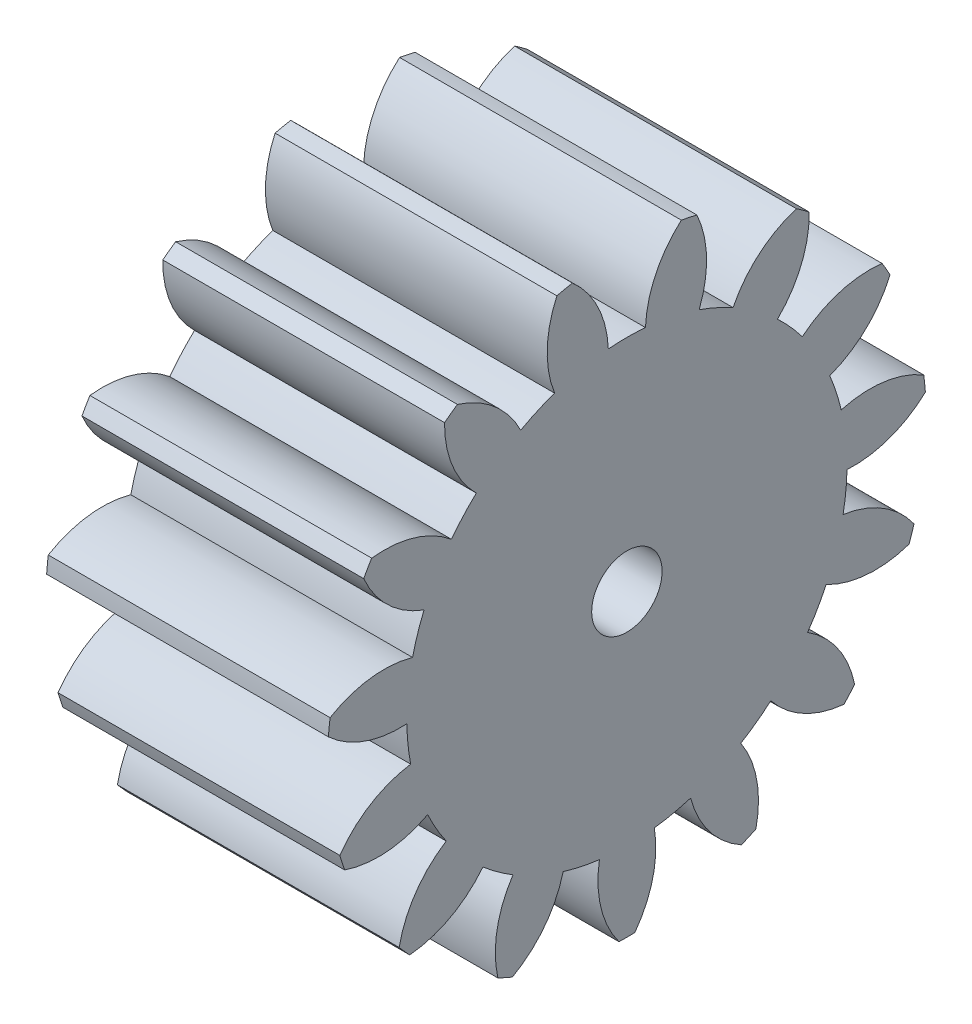
from build123d import *

# Parameters (mm, degrees)
BASPROSKE_W     = 20
BASPROSKE_H     = 21.25
TOOTHCUT_DEPTH  = 37.098822695
TEETHCUTS_COUNT = 15
TEETHCUTS_ANGLE = 336
BORSKE_R        = 2.5
BORE_DEPTH      = 50.0000508


with BuildPart() as part:
    # BasProSke → Base-Revolve (revolve)
    with BuildSketch(Plane(origin=(0, 0, 0), x_dir=(1, 0, 0), z_dir=(0, 1, 0)), mode=Mode.PRIVATE) as base_revolve_sk:
        with Locations((10, 10.625)):
            Rectangle(BASPROSKE_W, BASPROSKE_H)
    revolve(base_revolve_sk.sketch.rotate(Axis((-10, 0, 0), (1, 0, 0)), 180), axis=Axis((-10, 0, 0), (1, 0, 0)))

    # TooCutSke → ToothCut (cut, through all)
    with BuildSketch(Plane(origin=(0, 0, 0), x_dir=(0, 0, -1), z_dir=(1, 0, 0))):
        with BuildLine():
            ThreePointArc((1.317325472, 15.568366311), (0, 15.624), (-1.317325472, 15.568366311))
            ThreePointArc((-1.317325472, 15.568366311), (-2.05158513, 18.507838886), (-3.888921189, 20.916953343))
            ThreePointArc((-3.888921189, 20.916953343), (0, 21.2754), (3.888921189, 20.916953343))
            ThreePointArc((3.888921189, 20.916953343), (2.05158513, 18.507838886), (1.317325472, 15.568366311))
        make_face()
    toothcut = extrude(amount=TOOTHCUT_DEPTH, mode=Mode.SUBTRACT)

    # TeethCuts: ToothCut ×15 about axis
    teethcuts_axis = Axis((-10, 0, 0), (1, 0, 0))
    for i in range(1, TEETHCUTS_COUNT):
        add(toothcut.rotate(teethcuts_axis, i * TEETHCUTS_ANGLE / (TEETHCUTS_COUNT - 1)), mode=Mode.SUBTRACT)

    # BorSke → Bore (cut, symmetric)
    with BuildSketch(Plane(origin=(0, 0, 0), x_dir=(0, 0, -1), z_dir=(1, 0, 0))):
        with Locations(Location((0, 0, 0), (0, 0, 180))):
            Circle(BORSKE_R)
    extrude(amount=BORE_DEPTH, both=True, mode=Mode.SUBTRACT)


solid = part.part
